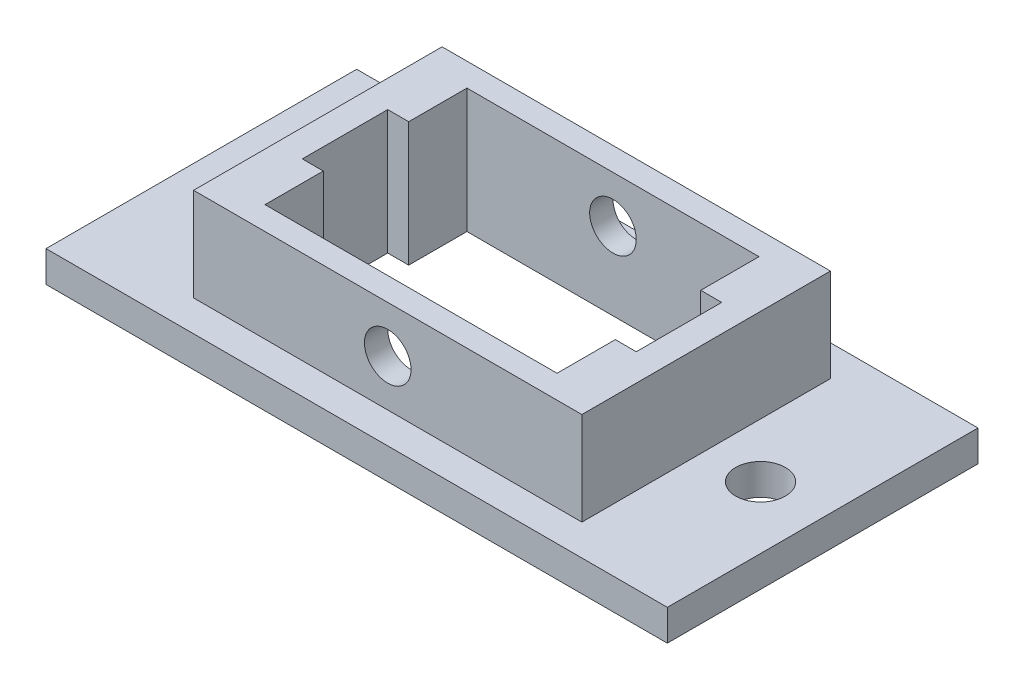
from build123d import *

# Parameters (mm, degrees)
SKETCH2_W           = 40
SKETCH2_H           = 20
BOSS_EXTRUDE1_DEPTH = 2
SKETCH3_W           = 25
SKETCH3_H           = 16
BOSS_EXTRUDE2_DEPTH = 8
CUT_EXTRUDE1_DEPTH  = 10
SKETCH5_R           = 1.6
CUT_EXTRUDE2_DEPTH  = 10
SKETCH6_R           = 1.5
CUT_EXTRUDE3_DEPTH  = 30


with BuildPart() as part:
    # Sketch2 → Boss-Extrude1 (new body)
    with BuildSketch(Plane(origin=(0, 0, 0), x_dir=(1, 0, 0), z_dir=(0, 1, 0))):
        with Locations((2.363636364, -3.454545455)):
            Rectangle(SKETCH2_W, SKETCH2_H)
    extrude(amount=BOSS_EXTRUDE1_DEPTH)

    # Sketch3 → Boss-Extrude2 (add)
    with BuildSketch(Plane.XZ):
        with Locations((2.363636364, 3.454545455)):
            Rectangle(SKETCH3_W, SKETCH3_H)
    extrude(amount=-BOSS_EXTRUDE2_DEPTH)

    # Sketch1 → Cut-Extrude1 (cut)
    with BuildSketch(Plane(origin=(0, 0, 0), x_dir=(1, 0, 0), z_dir=(0, 1, 0))):
        Polygon((-7.036363636, 3.045454545), (11.763636364, 3.045454545), (11.763636364, -0.704545455), (13.113636364, -0.704545455), (13.113636364, -6.204545455), (11.763636364, -6.204545455), (11.763636364, -9.954545455), (-7.036363636, -9.954545455), (-7.036363636, -6.204545455), (-8.386363636, -6.204545455), (-8.386363636, -0.704545455), (-7.036363636, -0.704545455), align=None)
    extrude(amount=CUT_EXTRUDE1_DEPTH, mode=Mode.SUBTRACT)

    # Sketch5 → Cut-Extrude2 (cut)
    with BuildSketch(Plane.XZ):
        with Locations((18.363636364, 3.454545455)):
            Circle(SKETCH5_R)
        with Locations((-13.636363636, 3.454545455)):
            Circle(SKETCH5_R)
    extrude(amount=-CUT_EXTRUDE2_DEPTH, mode=Mode.SUBTRACT)

    # Sketch6 → Cut-Extrude3 (cut)
    with BuildSketch(Plane.XY.offset(11.454545455)):
        with Locations((2.363636364, 5)):
            Circle(SKETCH6_R)
    extrude(amount=-CUT_EXTRUDE3_DEPTH, mode=Mode.SUBTRACT)


solid = part.part
